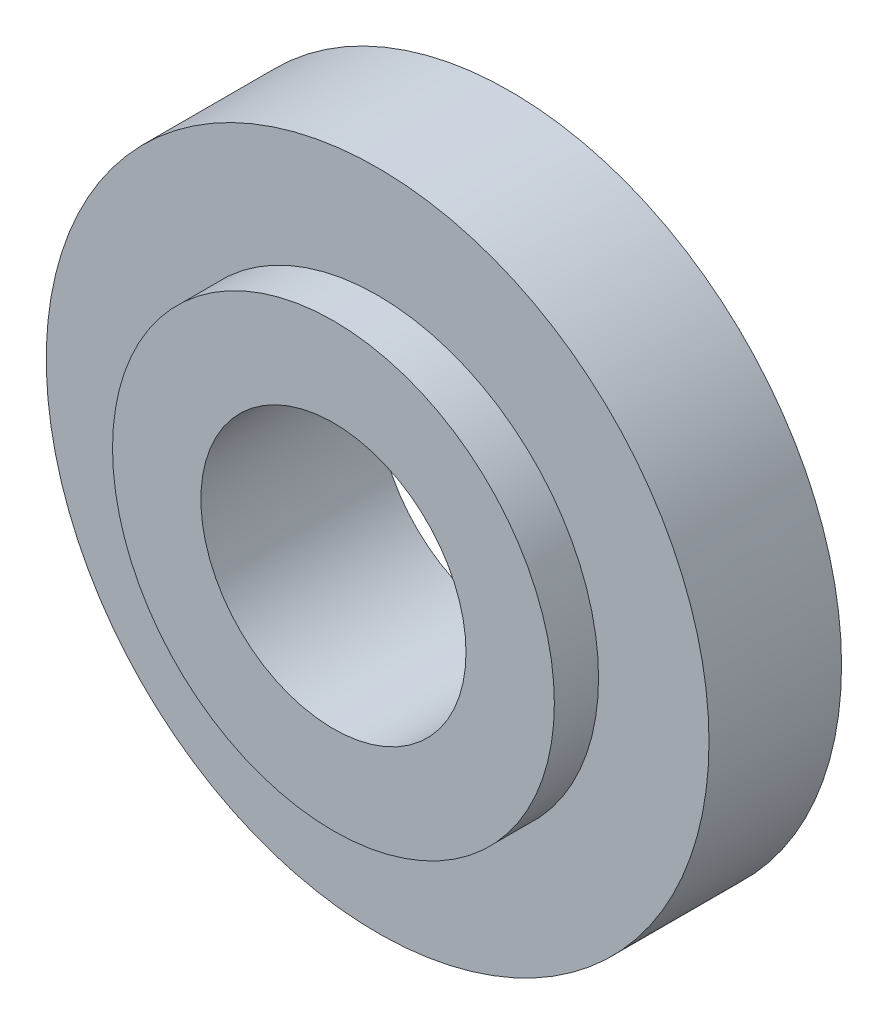
from build123d import *

# Parameters (mm, degrees)
SKETCH1_R           = 7.5
SKETCH1_R_2         = 3
BOSS_EXTRUDE1_DEPTH = 3
BOSS_EXTRUDE2_START = 1
SKETCH1_3_R         = 5
SKETCH1_3_R_2       = 3
BOSS_EXTRUDE2_DEPTH = 1


with BuildPart() as part:
    # Sketch1 → Boss-Extrude1 (new body)
    with BuildSketch(Plane.XY):
        Circle(SKETCH1_R)
        Circle(SKETCH1_R_2, mode=Mode.SUBTRACT)
    extrude(amount=-BOSS_EXTRUDE1_DEPTH)

    # Sketch1_3 → Boss-Extrude2 (add)
    with BuildSketch(Plane.XY.offset(BOSS_EXTRUDE2_START)):
        Circle(SKETCH1_3_R)
        Circle(SKETCH1_3_R_2, mode=Mode.SUBTRACT)
    extrude(amount=-BOSS_EXTRUDE2_DEPTH)


solid = part.part
